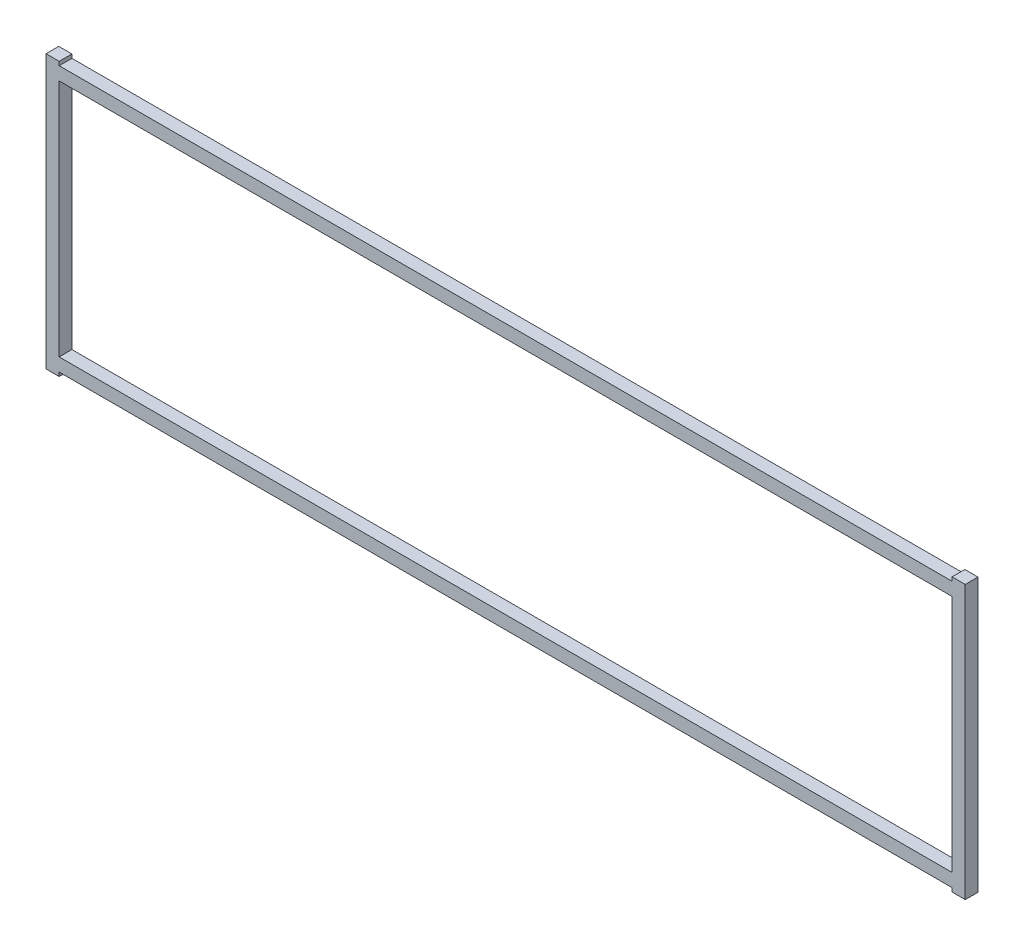
from build123d import *

# Parameters (mm, degrees)
SKETCH1_W           = 444.2968
SKETCH1_H           = 118.9228
BOSS_EXTRUDE1_DEPTH = 6.35


with BuildPart() as part:
    # Sketch1 → Boss-Extrude1 (new body)
    with BuildSketch(Plane.XY):
        Polygon((222.1484, -67.922775), (228.7016, -67.922775), (228.7016, 67.922775), (222.1484, 67.922775), (222.1484, 66.0146), (-222.1484, 66.0146), (-222.1484, 67.922775), (-228.7016, 67.922775), (-228.7016, -67.922775), (-222.1484, -67.922775), (-222.1484, -66.0146), (222.1484, -66.0146), align=None)
        Rectangle(SKETCH1_W, SKETCH1_H, mode=Mode.SUBTRACT)
    extrude(amount=BOSS_EXTRUDE1_DEPTH)


solid = part.part
